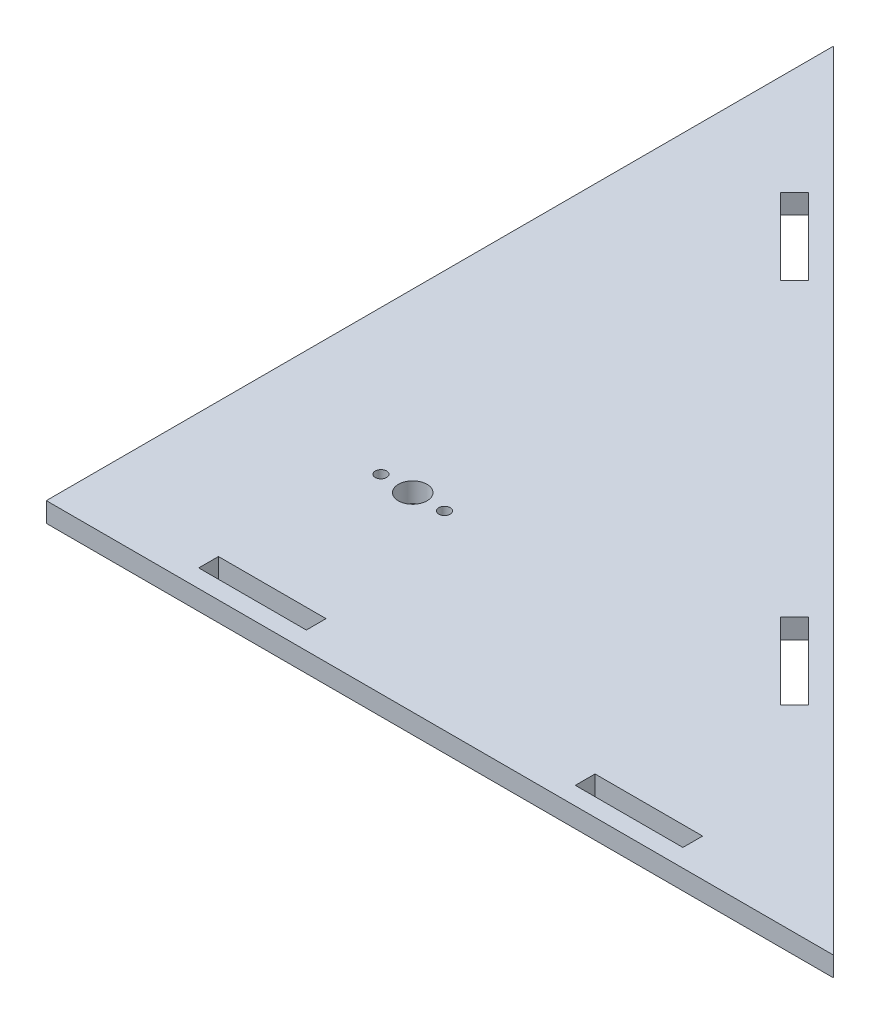
from build123d import *

# Parameters (mm, degrees)
SKETCH1_R           = 2.032
SKETCH1_R_2         = 0.80645
SKETCH1_W           = 15.24
SKETCH1_H           = 2.794
BOSS_EXTRUDE1_DEPTH = 2.794


with BuildPart() as part:
    # Sketch1 → Boss-Extrude1 (new body)
    with BuildSketch(Plane(origin=(0, 0, 0), x_dir=(1, 0, 0), z_dir=(0, 1, 0))):
        Polygon((0, 0), (111.5314, 0), (0, 111.5314), align=None)
        with Locations((24.965112017, 26.93738734)):
            Circle(SKETCH1_R, mode=Mode.SUBTRACT)
        with Locations((20.464232017, 26.93738734)):
            Circle(SKETCH1_R_2, mode=Mode.SUBTRACT)
        with Locations((29.465992017, 26.93738734)):
            Circle(SKETCH1_R_2, mode=Mode.SUBTRACT)
        with Locations((26.67, 3.937)):
            Rectangle(SKETCH1_W, SKETCH1_H, mode=Mode.SUBTRACT)
        with Locations((80.01, 3.937)):
            Rectangle(SKETCH1_W, SKETCH1_H, mode=Mode.SUBTRACT)
        Polygon((16.164461018, 91.774836534), (26.940768363, 80.998529188), (24.965112017, 79.022872842), (14.188804671, 89.799180187), align=None, mode=Mode.SUBTRACT)
        Polygon((68.24994652, 39.689351031), (79.026253865, 28.913043686), (77.050597519, 26.93738734), (66.274290173, 37.713694685), align=None, mode=Mode.SUBTRACT)
    extrude(amount=BOSS_EXTRUDE1_DEPTH)


solid = part.part
